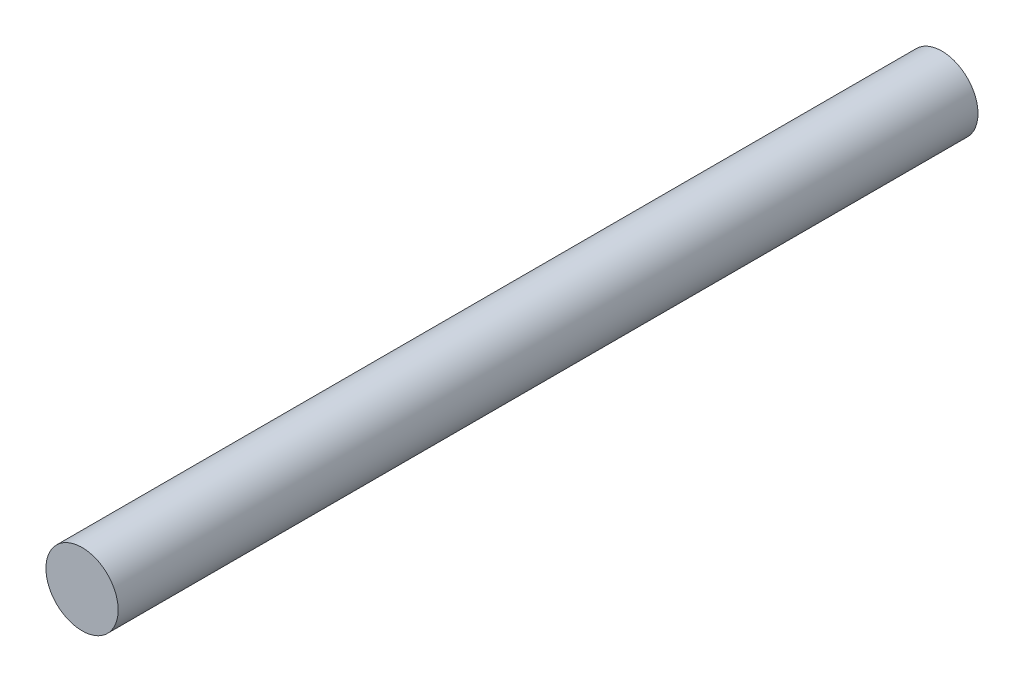
from build123d import *

# Parameters (mm, degrees)
SKETCH1_R      = 1.27
EXTRUDE1_DEPTH = 30.226


with BuildPart() as part:
    # Sketch1 → Extrude1 (new body)
    with BuildSketch(Plane.XY):
        Circle(SKETCH1_R)
    extrude(amount=EXTRUDE1_DEPTH)


solid = part.part
